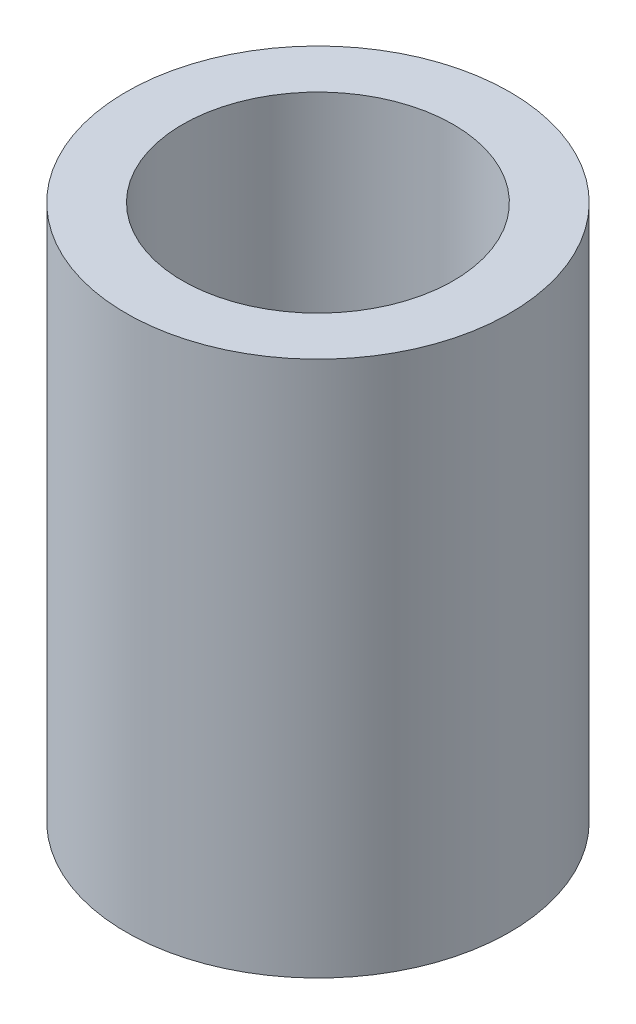
from build123d import *

# Parameters (mm, degrees)
CROQUIS1_W = 10
CROQUIS1_H = 95


with BuildPart() as part:
    # Croquis1 → Revolución1 (revolve)
    with BuildSketch(Plane.XY):
        with Locations((29, 47.5)):
            Rectangle(CROQUIS1_W, CROQUIS1_H)
    revolve(axis=Axis((0, 0, 0), (0, 1, 0)))


solid = part.part
